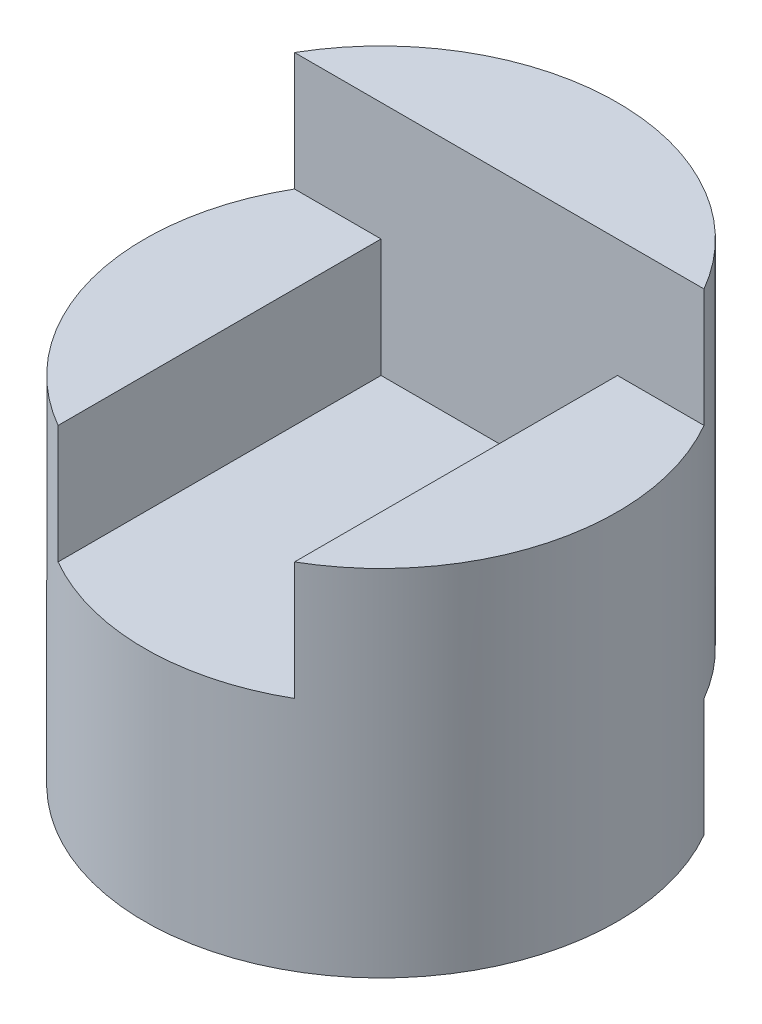
from build123d import *

# Parameters (mm, degrees)
SKETCH1_R               = 2
BOSS_EXTRUDE1_DEPTH     = 4
CUT_EXTRUDE1_DEPTH      = 3
CUT_EXTRUDE1_DEPTH_BACK = 1
CUT_EXTRUDE3_DEPTH      = 1


with BuildPart() as part:
    # Sketch1 → Boss-Extrude1 (new body)
    with BuildSketch(Plane(origin=(0, 0, 0), x_dir=(1, 0, 0), z_dir=(0, 1, 0))):
        Circle(SKETCH1_R)
    extrude(amount=BOSS_EXTRUDE1_DEPTH)

    # Sketch2 → Cut-Extrude1 (cut, two sides)
    with BuildSketch(Plane.XY) as cut_extrude1_sk:
        Polygon((-2, 4), (2, 4), (2, 3), (1, 3), (1, 2), (-1, 2), (-1, 3), (-2, 3), align=None)
    extrude(amount=CUT_EXTRUDE1_DEPTH, mode=Mode.SUBTRACT)
    extrude(cut_extrude1_sk.sketch, amount=-CUT_EXTRUDE1_DEPTH_BACK, mode=Mode.SUBTRACT)

    # Sketch4 → Cut-Extrude3 (cut)
    with BuildSketch(Plane.XZ):
        with BuildLine():
            Line((1.732050808, -1), (-1.732050808, -1))
            ThreePointArc((-1.732050808, -1), (0, -2), (1.732050808, -1))
        make_face()
    extrude(amount=-CUT_EXTRUDE3_DEPTH, mode=Mode.SUBTRACT)


solid = part.part
